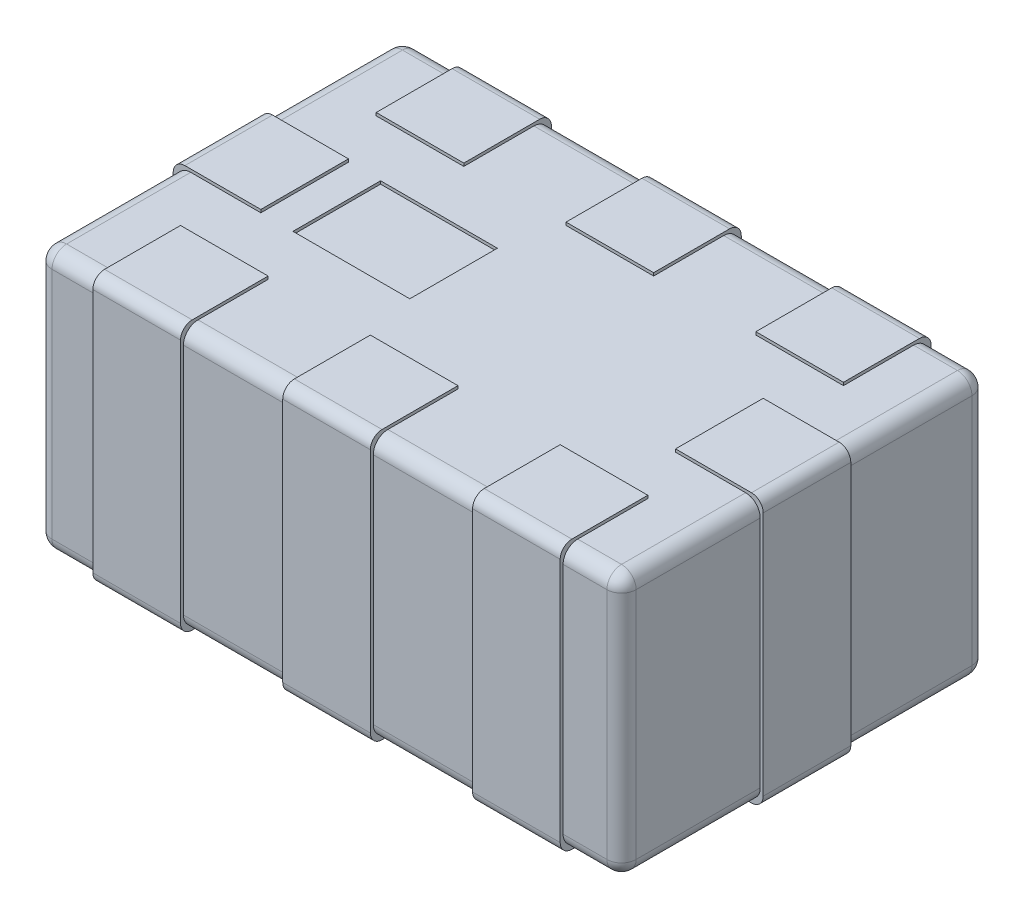
from build123d import *

# Parameters (mm, degrees)
SKETCH1_W           = 2
SKETCH1_H           = 1.25
BOSS_EXTRUDE1_DEPTH = 0.9
FILLET1_R           = 0.05
SKETCH2_W           = 0.3
SKETCH2_H           = 0.3
BOSS_EXTRUDE2_DEPTH = 0.01
SKETCH4_W           = 0.3
SKETCH4_H           = 0.3
BOSS_EXTRUDE3_DEPTH = 0.91
SKETCH3_W           = 0.4
SKETCH3_H           = 0.3
CUT_EXTRUDE1_DEPTH  = 0.01
FILLET2_R           = 0.04


with BuildPart() as part:
    # Sketch1 → Boss-Extrude1 (new body)
    with BuildSketch(Plane(origin=(0, 0, 0), x_dir=(1, 0, 0), z_dir=(0, 1, 0))):
        Rectangle(SKETCH1_W, SKETCH1_H)
    extrude(amount=BOSS_EXTRUDE1_DEPTH)

    # Fillet1
    fillet1_edges = [part.edges().sort_by_distance(p)[0] for p in [
        (-1, 0.9, 0),
        (0, 0.9, 0.625),
        (1, 0.9, 0),
        (0, 0, 0.625),
        (-1, 0, 0),
        (0, 0, -0.625),
        (1, 0, 0),
        (1, 0.45, 0.625),
        (-1, 0.45, 0.625),
        (-1, 0.45, -0.625),
        (1, 0.45, -0.625),
        (0, 0.9, -0.625),
    ]]
    fillet(fillet1_edges, radius=FILLET1_R)

    # Sketch2 → Boss-Extrude2 (add)
    with BuildSketch(Plane.XZ):
        with Locations((-0.86, 0)):
            Rectangle(SKETCH2_W, SKETCH2_H)
        with Locations((0.86, 0)):
            Rectangle(SKETCH2_W, SKETCH2_H)
        with Locations((-0.65, 0.485)):
            Rectangle(SKETCH2_W, SKETCH2_H)
        with Locations((0, 0.485)):
            Rectangle(SKETCH2_W, SKETCH2_H)
        with Locations((0.65, 0.485)):
            Rectangle(SKETCH2_W, SKETCH2_H)
        with Locations((0.65, -0.485)):
            Rectangle(SKETCH2_W, SKETCH2_H)
        with Locations((0, -0.485)):
            Rectangle(SKETCH2_W, SKETCH2_H)
        with Locations((-0.65, -0.485)):
            Rectangle(SKETCH2_W, SKETCH2_H)
    extrude(amount=BOSS_EXTRUDE2_DEPTH)

    # Sketch4 → Boss-Extrude3 (add)
    with BuildSketch(Plane.XZ):
        with Locations((-0.86, 0)):
            Rectangle(SKETCH4_W, SKETCH4_H)
        with Locations((0, 0.485)):
            Rectangle(SKETCH4_W, SKETCH4_H)
        with Locations((-0.65, 0.485)):
            Rectangle(SKETCH4_W, SKETCH4_H)
        with Locations((0.86, 0)):
            Rectangle(SKETCH4_W, SKETCH4_H)
        with Locations((-0.65, -0.485)):
            Rectangle(SKETCH4_W, SKETCH4_H)
        with Locations((0, -0.485)):
            Rectangle(SKETCH4_W, SKETCH4_H)
        with Locations((0.65, -0.485)):
            Rectangle(SKETCH4_W, SKETCH4_H)
        with Locations((0.65, 0.485)):
            Rectangle(SKETCH4_W, SKETCH4_H)
    extrude(amount=-BOSS_EXTRUDE3_DEPTH)

    # Sketch3 → Cut-Extrude1 (cut)
    with BuildSketch(Plane(origin=(0, 0.9, 0), x_dir=(1, 0, 0), z_dir=(0, 1, 0))):
        with Locations((-0.4, 0)):
            Rectangle(SKETCH3_W, SKETCH3_H)
    extrude(amount=-CUT_EXTRUDE1_DEPTH, mode=Mode.SUBTRACT)

    # Fillet2
    fillet2_edges = [part.edges().sort_by_distance(p)[0] for p in [
        (0.65, -0.01, 0.635),
        (0.65, -0.01, -0.635),
        (0, -0.01, -0.635),
        (-0.65, -0.01, -0.635),
        (-1.01, 0.91, 0),
        (0, 0.91, 0.635),
        (-0.65, 0.91, 0.635),
        (1.01, 0.91, 0),
        (-0.65, 0.91, -0.635),
        (0, 0.91, -0.635),
        (0.65, 0.91, -0.635),
        (0.65, 0.91, 0.635),
        (-1.01, -0.01, 0),
        (1.01, -0.01, 0),
        (-0.65, -0.01, 0.635),
        (0, -0.01, 0.635),
    ]]
    fillet(fillet2_edges, radius=FILLET2_R)


solid = part.part
